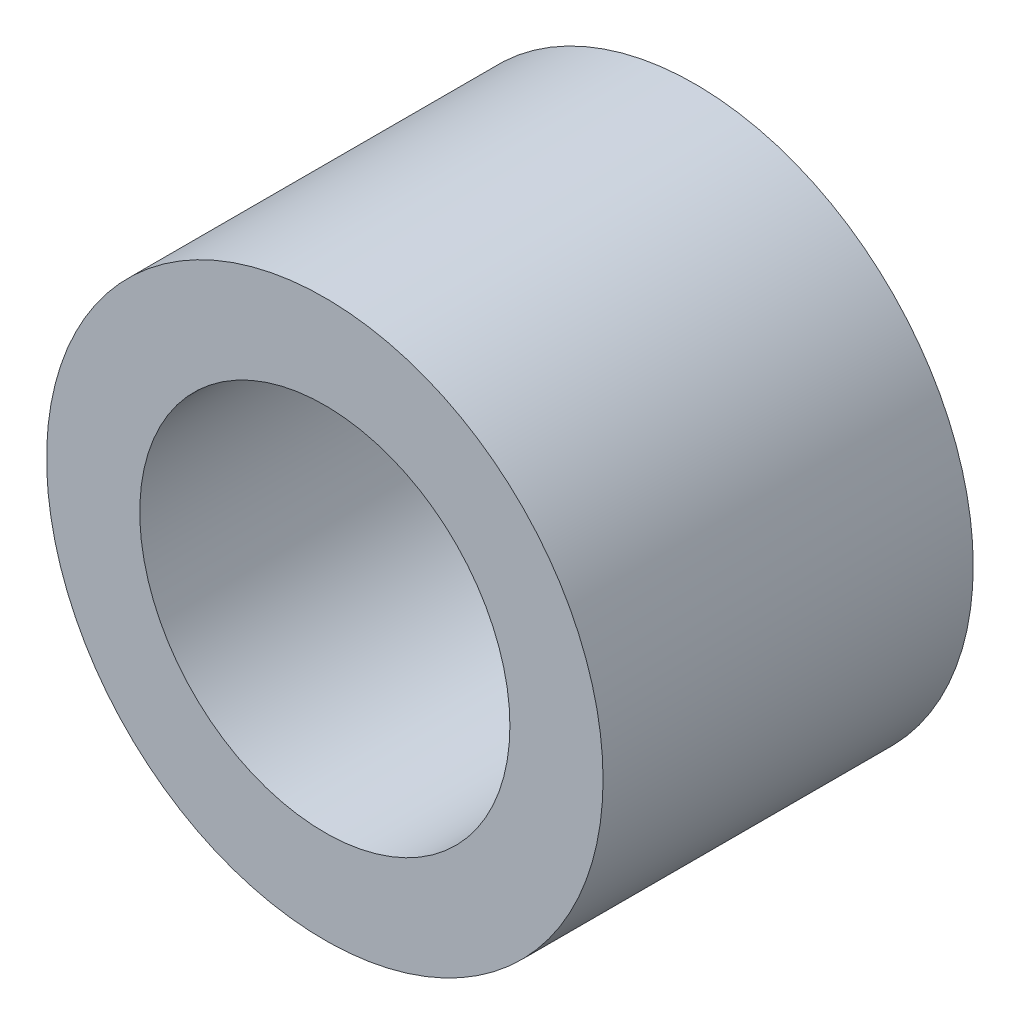
from build123d import *

# Parameters (mm, degrees)
SKETCH1_R      = 4.51
SKETCH1_R_2    = 3
EXTRUDE1_DEPTH = 3


with BuildPart() as part:
    # Sketch1 → Extrude1 (new body, symmetric)
    with BuildSketch(Plane.XY):
        Circle(SKETCH1_R)
        Circle(SKETCH1_R_2, mode=Mode.SUBTRACT)
    extrude(amount=EXTRUDE1_DEPTH, both=True)


solid = part.part
